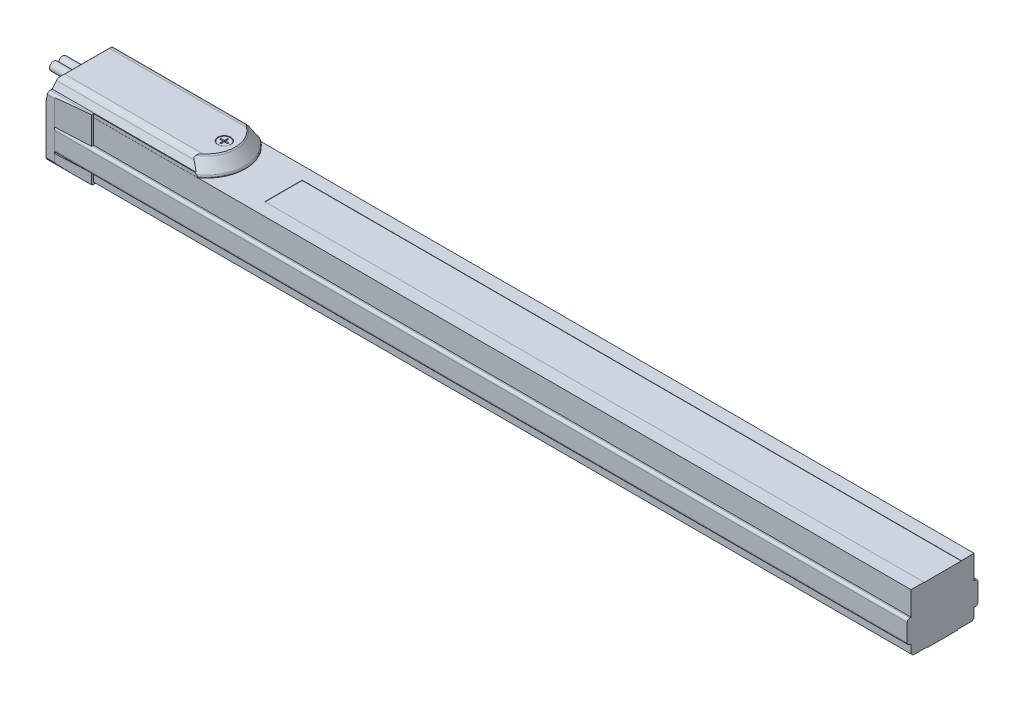
from build123d import *

# Parameters (mm, degrees)
BOSS_EXTRUDE1_DEPTH          = 930
SKETCH2_W                    = 204.786284779
SKETCH2_H                    = 168.647528641
CUT_EXTRUDE1_DEPTH           = 909.5
SKETCH3_W                    = 400
SKETCH3_H                    = 200
CUT_EXTRUDE2_DEPTH           = 930
BOSS_EXTRUDE2_DEPTH          = 127.35
CUT_REVOLVE1_ANGLE           = 75
CUT_REVOLVE1_OTHER_WAY_ANGLE = 75
CUT_EXTRUDE4_DEPTH           = 20
CUT_EXTRUDE5_DEPTH           = 1
CUT_EXTRUDE6_DEPTH           = 20
CUT_EXTRUDE6_DEPTH_BACK      = 20
CUT_EXTRUDE7_DEPTH           = 6
BOSS_EXTRUDE8_DEPTH          = 21.2
CUT_EXTRUDE9_DEPTH           = 30
CUT_EXTRUDE9_DEPTH_BACK      = 30
CUT_EXTRUDE10_DEPTH          = 2
CUT_EXTRUDE10_DEPTH_BACK     = 2
SKETCH14_R                   = 3.25
BOSS_EXTRUDE3_DEPTH          = 20
SKETCH15_R                   = 3.25
BOSS_EXTRUDE4_DEPTH          = 20
BOSS_EXTRUDE5_DEPTH          = 8.56
SKETCH17_W                   = 235.37802201
SKETCH17_H                   = 195.027503951
CUT_EXTRUDE14_DEPTH          = 40
BOSS_EXTRUDE6_DEPTH          = 18.5
BOSS_EXTRUDE7_DEPTH          = 8.56
SKETCH20_W                   = 235.37802201
SKETCH20_H                   = 195.027503951
CUT_EXTRUDE17_DEPTH          = 50
CUT_EXTRUDE18_DEPTH          = 3
SKETCH23_W                   = 742
SKETCH23_H                   = 29
CUT_EXTRUDE19_DEPTH          = 0.2
CUT_EXTRUDE20_DEPTH          = 25
CUT_EXTRUDE20_DEPTH_BACK     = 25
CUT_EXTRUDE21_DEPTH          = 16
CUT_EXTRUDE22_DEPTH          = 16
CUT_EXTRUDE23_DEPTH          = 34
CUT_EXTRUDE24_DEPTH          = 34
CUT_EXTRUDE25_DEPTH          = 16
CUT_EXTRUDE26_DEPTH          = 16
CUT_EXTRUDE27_DEPTH          = 12.5
CUT_EXTRUDE28_DEPTH          = 12.5
SKETCH_1_W                   = 185.367516804
SKETCH_1_H                   = 126.71742042
CUT_EXTRUDE_1_DEPTH          = 261


with BuildPart() as part:
    # Sketch1 → Boss-Extrude1 (new body)
    with BuildSketch(Plane(origin=(0, 0, 0), x_dir=(0, 0, -1), z_dir=(1, 0, 0))):
        with BuildLine():
            Line((-28.5, 46), (-28.5, 2.971392601))
            Line((-28.5, 2.971392601), (-27.5, 2.971392601))
            Line((-27.5, 2.971392601), (-27.328427125, 2.5))
            ThreePointArc((-27.328427125, 2.5), (-26.232050808, 1.050510257), (-24.5, 0.5))
            Line((-24.5, 0.5), (-12, 0.5))
            Line((-12, 0.5), (-11.5, 0))
            Line((-11.5, 0), (11.5, 0))
            Line((11.5, 0), (12, 0.5))
            Line((12, 0.5), (24.5, 0.5))
            ThreePointArc((24.5, 0.5), (26.232050808, 1.050510257), (27.328427125, 2.5))
            Line((27.328427125, 2.5), (27.5, 2.971392601))
            Line((27.5, 2.971392601), (28.5, 2.971392601))
            Line((28.5, 2.971392601), (28.5, 46))
            Line((28.5, 46), (27.5, 46))
            ThreePointArc((27.5, 46), (26.914213562, 47.414213562), (25.5, 48))
            Line((25.5, 48), (21.524012172, 48))
            ThreePointArc((21.524012172, 48), (17.477101448, 49.71603425), (13.295111884, 51.07))
            Line((13.295111884, 51.07), (-13.295111884, 51.07))
            ThreePointArc((-13.295111884, 51.07), (-17.477101448, 49.71603425), (-21.524012172, 48))
            Line((-21.524012172, 48), (-25.5, 48))
            ThreePointArc((-25.5, 48), (-26.914213562, 47.414213562), (-27.5, 46))
            Line((-27.5, 46), (-28.5, 46))
        make_face()
    extrude(amount=BOSS_EXTRUDE1_DEPTH)

    # Sketch2 → Cut-Extrude1 (cut)
    with BuildSketch(Plane(origin=(916, 0, 0), x_dir=(0, 0, -1), z_dir=(1, 0, 0))):
        with Locations((9.532349098, 15.424002622)):
            Rectangle(SKETCH2_W, SKETCH2_H)
        with BuildLine():
            Line((-27.5, 24.8), (-27.5, 11))
            ThreePointArc((-27.5, 11), (-26.914213562, 9.585786438), (-25.5, 9))
            Line((-25.5, 9), (-24.5, 9))
            Line((-24.5, 9), (-24.5, 2))
            Line((-24.5, 2), (-22.5, 0))
            Line((-22.5, 0), (22.5, 0))
            Line((22.5, 0), (24.5, 2))
            Line((24.5, 2), (24.5, 9))
            Line((24.5, 9), (25.5, 9))
            ThreePointArc((25.5, 9), (26.914213562, 9.585786438), (27.5, 11))
            Line((27.5, 11), (27.5, 24.8))
            ThreePointArc((27.5, 24.8), (26.914213562, 26.214213562), (25.5, 26.8))
            Line((25.5, 26.8), (24.5, 26.8))
            Line((24.5, 26.8), (24.5, 45.3))
            Line((24.5, 45.3), (-24.5, 45.3))
            Line((-24.5, 45.3), (-24.5, 26.8))
            Line((-24.5, 26.8), (-25.5, 26.8))
            ThreePointArc((-25.5, 26.8), (-26.914213562, 26.214213562), (-27.5, 24.8))
        make_face(mode=Mode.SUBTRACT)
    extrude(amount=-CUT_EXTRUDE1_DEPTH, mode=Mode.SUBTRACT)

    # Sketch3 → Cut-Extrude2 (cut)
    with BuildSketch(Plane(origin=(0, 0, 0), x_dir=(0, 0, -1), z_dir=(1, 0, 0))):
        Rectangle(SKETCH3_W, SKETCH3_H)
        with BuildLine():
            Line((-27.5, 46), (-27.5, 2.971392601))
            Line((-27.5, 2.971392601), (-27.328427125, 2.5))
            ThreePointArc((-27.328427125, 2.5), (-26.232050808, 1.050510257), (-24.5, 0.5))
            Line((-24.5, 0.5), (-12, 0.5))
            Line((-12, 0.5), (-11.5, 0))
            Line((-11.5, 0), (11.5, 0))
            Line((11.5, 0), (12, 0.5))
            Line((12, 0.5), (24.5, 0.5))
            ThreePointArc((24.5, 0.5), (26.232050808, 1.050510257), (27.328427125, 2.5))
            Line((27.328427125, 2.5), (27.5, 2.971392601))
            Line((27.5, 2.971392601), (27.5, 46))
            ThreePointArc((27.5, 46), (26.914213562, 47.414213562), (25.5, 48))
            Line((25.5, 48), (21.524012172, 48))
            ThreePointArc((21.524012172, 48), (17.477101448, 49.71603425), (13.295111884, 51.07))
            Line((13.295111884, 51.07), (-13.295111884, 51.07))
            ThreePointArc((-13.295111884, 51.07), (-17.477101448, 49.71603425), (-21.524012172, 48))
            Line((-21.524012172, 48), (-25.5, 48))
            ThreePointArc((-25.5, 48), (-26.914213562, 47.414213562), (-27.5, 46))
        make_face(mode=Mode.SUBTRACT)
    extrude(amount=CUT_EXTRUDE2_DEPTH, mode=Mode.SUBTRACT)

    # Sketch4 → Boss-Extrude2 (add)
    with BuildSketch(Plane(origin=(0, 0, 0), x_dir=(0, 0, -1), z_dir=(1, 0, 0))):
        with BuildLine():
            Line((-24.5, 30), (24.5, 30))
            Line((24.5, 30), (24.5, 45.3))
            Line((24.5, 45.3), (24.45, 45.3))
            Line((24.45, 45.3), (24.5, 45.35))
            Line((24.5, 45.35), (24.5, 48))
            Line((24.5, 48), (24, 48))
            Line((24, 48), (22.285663539, 52.710100717))
            ThreePointArc((22.285663539, 52.710100717), (20.455082617, 55.095760221), (17.587200435, 56))
            Line((17.587200435, 56), (-17.084187431, 56))
            ThreePointArc((-17.084187431, 56), (-19.770685472, 55.216957229), (-21.615726366, 53.113091309))
            Line((-21.615726366, 53.113091309), (-24, 48))
            Line((-24, 48), (-24.5, 48))
            Line((-24.5, 48), (-24.5, 45.35))
            Line((-24.5, 45.35), (-24.45, 45.3))
            Line((-24.45, 45.3), (-24.5, 45.3))
            Line((-24.5, 45.3), (-24.5, 30))
        make_face()
    extrude(amount=BOSS_EXTRUDE2_DEPTH)

    # Sketch5 → Cut-Revolve1 (revolve, cut)
    with BuildSketch(Plane.XY):
        with BuildLine():
            Line((97.35, 71.971261171), (150, 71.971261171))
            Line((150, 71.971261171), (150, 45.3))
            Line((150, 45.3), (127.35, 45.3))
            Line((127.35, 45.3), (127.35, 45.79))
            ThreePointArc((127.35, 45.79), (127.234272347, 46.460460828), (126.900482278, 47.053330799))
            Line((126.900482278, 47.053330799), (120.296542673, 55.158326997))
            ThreePointArc((120.296542673, 55.158326997), (118.566072869, 56.516172881), (116.420336979, 57))
            Line((116.420336979, 57), (97.35, 57))
            Line((97.35, 57), (97.35, 71.971261171))
        make_face()
    revolve(axis=Axis((97.35, 57, 0), (0, 1, 0)), revolution_arc=CUT_REVOLVE1_ANGLE, mode=Mode.SUBTRACT)

    # Sketch5 → Cut-Revolve1 other way (revolve, cut)
    with BuildSketch(Plane.XY):
        with BuildLine():
            Line((97.35, 71.971261171), (150, 71.971261171))
            Line((150, 71.971261171), (150, 45.3))
            Line((150, 45.3), (127.35, 45.3))
            Line((127.35, 45.3), (127.35, 45.79))
            ThreePointArc((127.35, 45.79), (127.234272347, 46.460460828), (126.900482278, 47.053330799))
            Line((126.900482278, 47.053330799), (120.296542673, 55.158326997))
            ThreePointArc((120.296542673, 55.158326997), (118.566072869, 56.516172881), (116.420336979, 57))
            Line((116.420336979, 57), (97.35, 57))
            Line((97.35, 57), (97.35, 71.971261171))
        make_face()
    revolve(axis=Axis((97.35, 57, 0), (0, -1, 0)), revolution_arc=CUT_REVOLVE1_OTHER_WAY_ANGLE, mode=Mode.SUBTRACT)

    # Sketch6 → Cut-Extrude4 (cut)
    with BuildSketch(Plane(origin=(0, 48, 0), x_dir=(-1, 0, 0), z_dir=(0, 1, 0))):
        Polygon((-916, 8.7), (-916.72022238, 8.7), (-926.5, 3.5), (-926.5, -3.5), (-916.72022238, -8.7), (-916, -8.7), align=None)
    extrude(amount=CUT_EXTRUDE4_DEPTH, mode=Mode.SUBTRACT)

    # Sketch7 → Revolve1 (revolve)
    with BuildSketch(Plane.XY):
        Polygon((921.5, 48), (918.5, 48), (918.5, 50.292893219), (919.207106781, 51), (921.5, 51), align=None)
    revolve(axis=Axis((921.5, 51, 0), (0, -1, 0)))

    # Sketch8 → Cut-Extrude5 (cut)
    with BuildSketch(Plane(origin=(0, 51, 0), x_dir=(-1, 0, 0), z_dir=(0, 1, 0))):
        with BuildLine():
            Line((-923.071623365, -0.3), (-921.8, -0.3))
            Line((-921.8, -0.3), (-921.8, -1.571623365))
            ThreePointArc((-921.8, -1.571623365), (-921.5, -1.6), (-921.2, -1.571623365))
            Line((-921.2, -1.571623365), (-921.2, -0.3))
            Line((-921.2, -0.3), (-919.928376635, -0.3))
            ThreePointArc((-919.928376635, -0.3), (-919.9, 0), (-919.928376635, 0.3))
            Line((-919.928376635, 0.3), (-921.2, 0.3))
            Line((-921.2, 0.3), (-921.2, 1.571623365))
            ThreePointArc((-921.2, 1.571623365), (-921.5, 1.6), (-921.8, 1.571623365))
            Line((-921.8, 1.571623365), (-921.8, 0.3))
            Line((-921.8, 0.3), (-923.071623365, 0.3))
            ThreePointArc((-923.071623365, 0.3), (-923.1, 0), (-923.071623365, -0.3))
        make_face()
    extrude(amount=-CUT_EXTRUDE5_DEPTH, mode=Mode.SUBTRACT)

    # Sketch9 → Cut-Extrude6 (cut, two sides)
    with BuildSketch(Plane.XY) as cut_extrude6_sk:
        Polygon((-50, 0.5), (-50, 0), (79, 0), (78.5, 0.5), align=None)
    extrude(amount=CUT_EXTRUDE6_DEPTH, mode=Mode.SUBTRACT)
    extrude(cut_extrude6_sk.sketch, amount=-CUT_EXTRUDE6_DEPTH_BACK, mode=Mode.SUBTRACT)

    # Sketch10 → Cut-Extrude7 (cut)
    with BuildSketch(Plane(origin=(0, 0, 0), x_dir=(-1, 0, 0), z_dir=(0, 1, 0))):
        with BuildLine():
            Line((-625.5, 2), (-627.5, 2))
            ThreePointArc((-627.5, 2), (-629.5, 0), (-627.5, -2))
            Line((-627.5, -2), (-625.5, -2))
            ThreePointArc((-625.5, -2), (-623.5, 0), (-625.5, 2))
        make_face()
    extrude(amount=CUT_EXTRUDE7_DEPTH, mode=Mode.SUBTRACT)

    # Sketch11 → Boss-Extrude8 (add)
    with BuildSketch(Plane(origin=(0, 26.8, 0), x_dir=(-1, 0, 0), z_dir=(0, 1, 0))):
        Polygon((0, 27.5), (-6, 27.5), (-34, 26.1), (-34, -26.1), (-6, -27.5), (0, -27.5), align=None)
    extrude(amount=BOSS_EXTRUDE8_DEPTH)

    # Sketch12 → Cut-Extrude9 (cut, two sides)
    with BuildSketch(Plane.XY) as cut_extrude9_sk:
        with BuildLine():
            Line((-20, -15), (15, -15))
            Line((15, -15), (15, 0))
            Line((15, 0), (5.587775501, 0))
            ThreePointArc((5.587775501, 0), (2.209824463, 1.313613316), (0.60680201, 4.564221286))
            Line((0.60680201, 4.564221286), (0, 11.5))
            Line((0, 11.5), (0, 40.45))
            Line((0, 40.45), (2.189670922, 52.868240888))
            ThreePointArc((2.189670922, 52.868240888), (3.899771638, 55.830222216), (7.113709687, 57))
            Line((7.113709687, 57), (15, 57))
            Line((15, 57), (15, 60))
            Line((15, 60), (-20, 60))
            Line((-20, 60), (-20, -15))
        make_face()
    extrude(amount=CUT_EXTRUDE9_DEPTH, mode=Mode.SUBTRACT)
    extrude(cut_extrude9_sk.sketch, amount=-CUT_EXTRUDE9_DEPTH_BACK, mode=Mode.SUBTRACT)

    # Sketch13 → Cut-Extrude10 (cut, two sides)
    with BuildSketch(Plane(origin=(0, 0, 0), x_dir=(0, 0, -1), z_dir=(1, 0, 0))) as cut_extrude10_sk:
        with BuildLine():
            Line((-10, 46.95), (-10, 42.95))
            ThreePointArc((-10, 42.95), (-8.535533906, 39.414466094), (-5, 37.95))
            Line((-5, 37.95), (5, 37.95))
            ThreePointArc((5, 37.95), (8.535533906, 39.414466094), (10, 42.95))
            Line((10, 42.95), (10, 46.95))
            ThreePointArc((10, 46.95), (9.707106781, 47.657106781), (9, 47.95))
            Line((9, 47.95), (-9, 47.95))
            ThreePointArc((-9, 47.95), (-9.707106781, 47.657106781), (-10, 46.95))
        make_face()
    extrude(amount=CUT_EXTRUDE10_DEPTH, mode=Mode.SUBTRACT)
    extrude(cut_extrude10_sk.sketch, amount=-CUT_EXTRUDE10_DEPTH_BACK, mode=Mode.SUBTRACT)

    # Sketch14 → Boss-Extrude3 (add)
    with BuildSketch(Plane(origin=(2, 0, 0), x_dir=(0, 0, -1), z_dir=(1, 0, 0))):
        with Locations((-3.5, 43.7)):
            Circle(SKETCH14_R)
    extrude(amount=-BOSS_EXTRUDE3_DEPTH)

    # Sketch15 → Boss-Extrude4 (add)
    with BuildSketch(Plane(origin=(2, 0, 0), x_dir=(0, 0, -1), z_dir=(1, 0, 0))):
        with Locations((3.5, 43.7)):
            Circle(SKETCH15_R)
    extrude(amount=-BOSS_EXTRUDE4_DEPTH)

    # Sketch16 → Boss-Extrude5 (add)
    with BuildSketch(Plane(origin=(0, 9, 0), x_dir=(-1, 0, 0), z_dir=(0, 1, 0))):
        Polygon((0, 27.5), (-6, 27.5), (-34, 26.1), (-34, -26.1), (-6, -27.5), (0, -27.5), align=None)
    extrude(amount=-BOSS_EXTRUDE5_DEPTH)

    # Sketch17 → Cut-Extrude14 (cut)
    with BuildSketch(Plane(origin=(0, 0, 0), x_dir=(0, 0, -1), z_dir=(1, 0, 0))):
        with Locations((8.296344577, 18.152881027)):
            Rectangle(SKETCH17_W, SKETCH17_H)
        with BuildLine():
            Line((-27.5, 46), (-27.5, 2.971392601))
            Line((-27.5, 2.971392601), (-27.328427125, 2.5))
            ThreePointArc((-27.328427125, 2.5), (-26.232050808, 1.050510257), (-24.5, 0.5))
            Line((-24.5, 0.5), (24.5, 0.5))
            ThreePointArc((24.5, 0.5), (26.232050808, 1.050510257), (27.328427125, 2.5))
            Line((27.328427125, 2.5), (27.5, 2.971392601))
            Line((27.5, 2.971392601), (27.5, 46))
            ThreePointArc((27.5, 46), (26.914213562, 47.414213562), (25.5, 48))
            Line((25.5, 48), (24, 48))
            Line((24, 48), (24, 65))
            Line((24, 65), (-24, 65))
            Line((-24, 65), (-24, 48))
            Line((-24, 48), (-25.5, 48))
            ThreePointArc((-25.5, 48), (-26.914213562, 47.414213562), (-27.5, 46))
        make_face(mode=Mode.SUBTRACT)
    extrude(amount=CUT_EXTRUDE14_DEPTH, mode=Mode.SUBTRACT)

    # Sketch18 → Boss-Extrude6 (add)
    with BuildSketch(Plane(origin=(0, 26.8, 0), x_dir=(-1, 0, 0), z_dir=(0, 1, 0))):
        Polygon((-889, 26.1), (-917, 27.5), (-923, 27.5), (-923, -27.5), (-917, -27.5), (-889, -26.1), align=None)
    extrude(amount=BOSS_EXTRUDE6_DEPTH)

    # Sketch19 → Boss-Extrude7 (add)
    with BuildSketch(Plane(origin=(0, 9, 0), x_dir=(-1, 0, 0), z_dir=(0, 1, 0))):
        Polygon((-889, 26.1), (-917, 27.5), (-930, 27.5), (-930, -27.5), (-917, -27.5), (-889, -26.1), align=None)
    extrude(amount=-BOSS_EXTRUDE7_DEPTH)

    # Sketch20 → Cut-Extrude17 (cut)
    with BuildSketch(Plane(origin=(930, 0, 0), x_dir=(0, 0, -1), z_dir=(1, 0, 0))):
        with Locations((8.296344577, 18.152881027)):
            Rectangle(SKETCH20_W, SKETCH20_H)
        with BuildLine():
            Line((-27.5, 46), (-27.5, 2.971392601))
            Line((-27.5, 2.971392601), (-27.328427125, 2.5))
            ThreePointArc((-27.328427125, 2.5), (-26.232050808, 1.050510257), (-24.5, 0.5))
            Line((-24.5, 0.5), (-12, 0.5))
            Line((-12, 0.5), (-11.5, 0))
            Line((-11.5, 0), (11.5, 0))
            Line((11.5, 0), (12, 0.5))
            Line((12, 0.5), (24.5, 0.5))
            ThreePointArc((24.5, 0.5), (26.232050808, 1.050510257), (27.328427125, 2.5))
            Line((27.328427125, 2.5), (27.5, 2.971392601))
            Line((27.5, 2.971392601), (27.5, 46))
            ThreePointArc((27.5, 46), (26.914213562, 47.414213562), (25.5, 48))
            Line((25.5, 48), (24, 48))
            Line((24, 48), (24, 65))
            Line((24, 65), (-24, 65))
            Line((-24, 65), (-24, 48))
            Line((-24, 48), (-25.5, 48))
            ThreePointArc((-25.5, 48), (-26.914213562, 47.414213562), (-27.5, 46))
        make_face(mode=Mode.SUBTRACT)
    extrude(amount=-CUT_EXTRUDE17_DEPTH, mode=Mode.SUBTRACT)

    # Sketch21 → Cut-Revolve2 (revolve, cut)
    with BuildSketch(Plane.XY):
        Polygon((111, 60.83306822), (116, 60.83306822), (116, 55.5), (115.7, 55.8), (111, 55.8), align=None)
    revolve(axis=Axis((111, 55.8, 0), (0, 1, 0)), mode=Mode.SUBTRACT)

    # Sketch22 → Cut-Extrude18 (cut)
    with BuildSketch(Plane(origin=(0, 55.8, 0), x_dir=(-1, 0, 0), z_dir=(0, 1, 0))):
        with BuildLine():
            Line((-108.041960108, 0.5), (-110.5, 0.5))
            Line((-110.5, 0.5), (-110.5, 2.958039892))
            ThreePointArc((-110.5, 2.958039892), (-111, 3), (-111.5, 2.958039892))
            Line((-111.5, 2.958039892), (-111.5, 0.5))
            Line((-111.5, 0.5), (-113.958039892, 0.5))
            ThreePointArc((-113.958039892, 0.5), (-114, 0), (-113.958039892, -0.5))
            Line((-113.958039892, -0.5), (-111.5, -0.5))
            Line((-111.5, -0.5), (-111.5, -2.958039892))
            ThreePointArc((-111.5, -2.958039892), (-111, -3), (-110.5, -2.958039892))
            Line((-110.5, -2.958039892), (-110.5, -0.5))
            Line((-110.5, -0.5), (-108.041960108, -0.5))
            ThreePointArc((-108.041960108, -0.5), (-108, 0), (-108.041960108, 0.5))
        make_face()
    extrude(amount=-CUT_EXTRUDE18_DEPTH, mode=Mode.SUBTRACT)

    # Sketch23 → Cut-Extrude19 (cut)
    with BuildSketch(Plane(origin=(0, 45.3, 0), x_dir=(-1, 0, 0), z_dir=(0, 1, 0))):
        with Locations((-528, 0)):
            Rectangle(SKETCH23_W, SKETCH23_H)
    extrude(amount=-CUT_EXTRUDE19_DEPTH, mode=Mode.SUBTRACT)

    # Sketch24 → Cut-Revolve3 (revolve, cut)
    with BuildSketch(Plane.XY):
        Polygon((126.5, 0), (124.5, 0), (124.5, 6), (126.5, 7.154700538), align=None)
    revolve(axis=Axis((126.5, 7.154700538, 0), (0, -1, 0)), mode=Mode.SUBTRACT)

    # Sketch25 → Cut-Revolve4 (revolve, cut)
    with BuildSketch(Plane(origin=(101.5, 0, 0), x_dir=(0, 0, -1), z_dir=(1, 0, 0))):
        Polygon((0, 11.019415637), (2.4585, 9.6), (2.4585, 0.5415), (3, 0), (0, 0), align=None)
    revolve(axis=Axis((101.5, 0, 0), (0, 1, 0)), mode=Mode.SUBTRACT)

    # Sketch26 → Cut-Revolve5 (revolve, cut)
    with BuildSketch(Plane(origin=(901.5, 0, 0), x_dir=(0, 0, -1), z_dir=(1, 0, 0))):
        Polygon((0, 11.019415637), (2.4585, 9.6), (2.4585, 0.5415), (3, 0), (0, 0), align=None)
    revolve(axis=Axis((901.5, 0, 0), (0, 1, 0)), mode=Mode.SUBTRACT)

    # Sketch27 → Cut-Revolve6 (revolve, cut)
    with BuildSketch(Plane(origin=(851.5, 0, 0), x_dir=(0, 0, -1), z_dir=(1, 0, 0))):
        Polygon((0, 11.019415637), (2.4585, 9.6), (2.4585, 0.5415), (3, 0), (0, 0), align=None)
    revolve(axis=Axis((851.5, 0, 0), (0, 1, 0)), mode=Mode.SUBTRACT)

    # Sketch28 → Cut-Revolve7 (revolve, cut)
    with BuildSketch(Plane(origin=(801.5, 0, 0), x_dir=(0, 0, -1), z_dir=(1, 0, 0))):
        Polygon((0, 11.019415637), (2.4585, 9.6), (2.4585, 0.5415), (3, 0), (0, 0), align=None)
    revolve(axis=Axis((801.5, 0, 0), (0, 1, 0)), mode=Mode.SUBTRACT)

    # Sketch29 → Cut-Revolve8 (revolve, cut)
    with BuildSketch(Plane(origin=(751.5, 0, 0), x_dir=(0, 0, -1), z_dir=(1, 0, 0))):
        Polygon((0, 11.019415637), (2.4585, 9.6), (2.4585, 0.5415), (3, 0), (0, 0), align=None)
    revolve(axis=Axis((751.5, 0, 0), (0, 1, 0)), mode=Mode.SUBTRACT)

    # Sketch30 → Cut-Revolve9 (revolve, cut)
    with BuildSketch(Plane(origin=(701.5, 0, 0), x_dir=(0, 0, -1), z_dir=(1, 0, 0))):
        Polygon((0, 11.019415637), (2.4585, 9.6), (2.4585, 0.5415), (3, 0), (0, 0), align=None)
    revolve(axis=Axis((701.5, 0, 0), (0, 1, 0)), mode=Mode.SUBTRACT)

    # Sketch31 → Cut-Revolve10 (revolve, cut)
    with BuildSketch(Plane(origin=(651.5, 0, 0), x_dir=(0, 0, -1), z_dir=(1, 0, 0))):
        Polygon((0, 11.019415637), (2.4585, 9.6), (2.4585, 0.5415), (3, 0), (0, 0), align=None)
    revolve(axis=Axis((651.5, 0, 0), (0, 1, 0)), mode=Mode.SUBTRACT)

    # Sketch32 → Cut-Revolve11 (revolve, cut)
    with BuildSketch(Plane(origin=(601.5, 0, 0), x_dir=(0, 0, -1), z_dir=(1, 0, 0))):
        Polygon((0, 11.019415637), (2.4585, 9.6), (2.4585, 0.5415), (3, 0), (0, 0), align=None)
    revolve(axis=Axis((601.5, 0, 0), (0, 1, 0)), mode=Mode.SUBTRACT)

    # Sketch33 → Cut-Revolve12 (revolve, cut)
    with BuildSketch(Plane(origin=(551.5, 0, 0), x_dir=(0, 0, -1), z_dir=(1, 0, 0))):
        Polygon((0, 11.019415637), (2.4585, 9.6), (2.4585, 0.5415), (3, 0), (0, 0), align=None)
    revolve(axis=Axis((551.5, 0, 0), (0, 1, 0)), mode=Mode.SUBTRACT)

    # Sketch34 → Cut-Revolve13 (revolve, cut)
    with BuildSketch(Plane(origin=(501.5, 0, 0), x_dir=(0, 0, -1), z_dir=(1, 0, 0))):
        Polygon((0, 11.019415637), (2.4585, 9.6), (2.4585, 0.5415), (3, 0), (0, 0), align=None)
    revolve(axis=Axis((501.5, 0, 0), (0, 1, 0)), mode=Mode.SUBTRACT)

    # Sketch35 → Cut-Revolve14 (revolve, cut)
    with BuildSketch(Plane(origin=(451.5, 0, 0), x_dir=(0, 0, -1), z_dir=(1, 0, 0))):
        Polygon((0, 11.019415637), (2.4585, 9.6), (2.4585, 0.5415), (3, 0), (0, 0), align=None)
    revolve(axis=Axis((451.5, 0, 0), (0, 1, 0)), mode=Mode.SUBTRACT)

    # Sketch36 → Cut-Revolve15 (revolve, cut)
    with BuildSketch(Plane(origin=(401.5, 0, 0), x_dir=(0, 0, -1), z_dir=(1, 0, 0))):
        Polygon((0, 11.019415637), (2.4585, 9.6), (2.4585, 0.5415), (3, 0), (0, 0), align=None)
    revolve(axis=Axis((401.5, 0, 0), (0, 1, 0)), mode=Mode.SUBTRACT)

    # Sketch37 → Cut-Revolve16 (revolve, cut)
    with BuildSketch(Plane(origin=(351.5, 0, 0), x_dir=(0, 0, -1), z_dir=(1, 0, 0))):
        Polygon((0, 11.019415637), (2.4585, 9.6), (2.4585, 0.5415), (3, 0), (0, 0), align=None)
    revolve(axis=Axis((351.5, 0, 0), (0, 1, 0)), mode=Mode.SUBTRACT)

    # Sketch38 → Cut-Revolve17 (revolve, cut)
    with BuildSketch(Plane(origin=(301.5, 0, 0), x_dir=(0, 0, -1), z_dir=(1, 0, 0))):
        Polygon((0, 11.019415637), (2.4585, 9.6), (2.4585, 0.5415), (3, 0), (0, 0), align=None)
    revolve(axis=Axis((301.5, 0, 0), (0, 1, 0)), mode=Mode.SUBTRACT)

    # Sketch39 → Cut-Revolve18 (revolve, cut)
    with BuildSketch(Plane(origin=(251.5, 0, 0), x_dir=(0, 0, -1), z_dir=(1, 0, 0))):
        Polygon((0, 11.019415637), (2.4585, 9.6), (2.4585, 0.5415), (3, 0), (0, 0), align=None)
    revolve(axis=Axis((251.5, 0, 0), (0, 1, 0)), mode=Mode.SUBTRACT)

    # Sketch40 → Cut-Revolve19 (revolve, cut)
    with BuildSketch(Plane(origin=(201.5, 0, 0), x_dir=(0, 0, -1), z_dir=(1, 0, 0))):
        Polygon((0, 11.019415637), (2.4585, 9.6), (2.4585, 0.5415), (3, 0), (0, 0), align=None)
    revolve(axis=Axis((201.5, 0, 0), (0, 1, 0)), mode=Mode.SUBTRACT)

    # Sketch41 → Cut-Revolve20 (revolve, cut)
    with BuildSketch(Plane(origin=(151.5, 0, 0), x_dir=(0, 0, -1), z_dir=(1, 0, 0))):
        Polygon((0, 11.019415637), (2.4585, 9.6), (2.4585, 0.5415), (3, 0), (0, 0), align=None)
    revolve(axis=Axis((151.5, 0, 0), (0, 1, 0)), mode=Mode.SUBTRACT)

    # Sketch42 → Cut-Extrude20 (cut, two sides)
    with BuildSketch(Plane.XY) as cut_extrude20_sk:
        Polygon((34, 0.5), (34.05, 0.5), (34, 0.55), align=None)
    extrude(amount=CUT_EXTRUDE20_DEPTH, mode=Mode.SUBTRACT)
    extrude(cut_extrude20_sk.sketch, amount=-CUT_EXTRUDE20_DEPTH_BACK, mode=Mode.SUBTRACT)

    # Sketch43 → Cut-Extrude21 (cut)
    with BuildSketch(Plane(origin=(0, 26.8, 0), x_dir=(-1, 0, 0), z_dir=(0, 1, 0))):
        Polygon((-6.5, 27.5), (-6.55, 27.5), (-6.5, 27.45), align=None)
    extrude(amount=-CUT_EXTRUDE21_DEPTH, mode=Mode.SUBTRACT)

    # Sketch44 → Cut-Extrude22 (cut)
    with BuildSketch(Plane(origin=(0, 26.8, 0), x_dir=(-1, 0, 0), z_dir=(0, 1, 0))):
        Polygon((-6.5, -27.5), (-6.5, -27.45), (-6.55, -27.5), align=None)
    extrude(amount=-CUT_EXTRUDE22_DEPTH, mode=Mode.SUBTRACT)

    # Sketch45 → Cut-Extrude23 (cut)
    with BuildSketch(Plane(origin=(916, 0, 0), x_dir=(0, 0, -1), z_dir=(1, 0, 0))):
        Polygon((-24.558, 45.3), (-24.5, 45.25), (-24.5, 45.3), align=None)
    extrude(amount=-CUT_EXTRUDE23_DEPTH, mode=Mode.SUBTRACT)

    # Sketch46 → Cut-Extrude24 (cut)
    with BuildSketch(Plane(origin=(916, 0, 0), x_dir=(0, 0, -1), z_dir=(1, 0, 0))):
        Polygon((24.5, 45.25), (24.558, 45.3), (24.5, 45.3), align=None)
    extrude(amount=-CUT_EXTRUDE24_DEPTH, mode=Mode.SUBTRACT)

    # Sketch47 → Cut-Extrude25 (cut)
    with BuildSketch(Plane(origin=(0, 26.8, 0), x_dir=(-1, 0, 0), z_dir=(0, 1, 0))):
        Polygon((-915.95, 27.5), (-916, 27.5), (-916, 27.45), align=None)
    extrude(amount=-CUT_EXTRUDE25_DEPTH, mode=Mode.SUBTRACT)

    # Sketch48 → Cut-Extrude26 (cut)
    with BuildSketch(Plane(origin=(0, 26.8, 0), x_dir=(-1, 0, 0), z_dir=(0, 1, 0))):
        Polygon((-915.95, -27.5), (-916, -27.45), (-916, -27.5), align=None)
    extrude(amount=-CUT_EXTRUDE26_DEPTH, mode=Mode.SUBTRACT)

    # Sketch49 → Cut-Extrude27 (cut)
    with BuildSketch(Plane.XY.offset(24.5)):
        Polygon((888.95, 0.5), (889, 0.5), (889, 0.55), align=None)
    extrude(amount=-CUT_EXTRUDE27_DEPTH, mode=Mode.SUBTRACT)

    # Sketch50 → Cut-Extrude28 (cut)
    with BuildSketch(Plane.XY.offset(-24.5)):
        Polygon((888.95, 0.5), (889, 0.5), (889, 0.55), align=None)
    extrude(amount=CUT_EXTRUDE28_DEPTH, mode=Mode.SUBTRACT)

    # Эскиз1 → Вырез-Вытянуть1 (cut)
    with BuildSketch(Plane(origin=(930, 0, 0), x_dir=(0, 0, -1), z_dir=(1, 0, 0))):
        with Locations((1.329004423, 33.558913214)):
            Rectangle(SKETCH_1_W, SKETCH_1_H)
    extrude(amount=-CUT_EXTRUDE_1_DEPTH, mode=Mode.SUBTRACT)


solid = part.part
